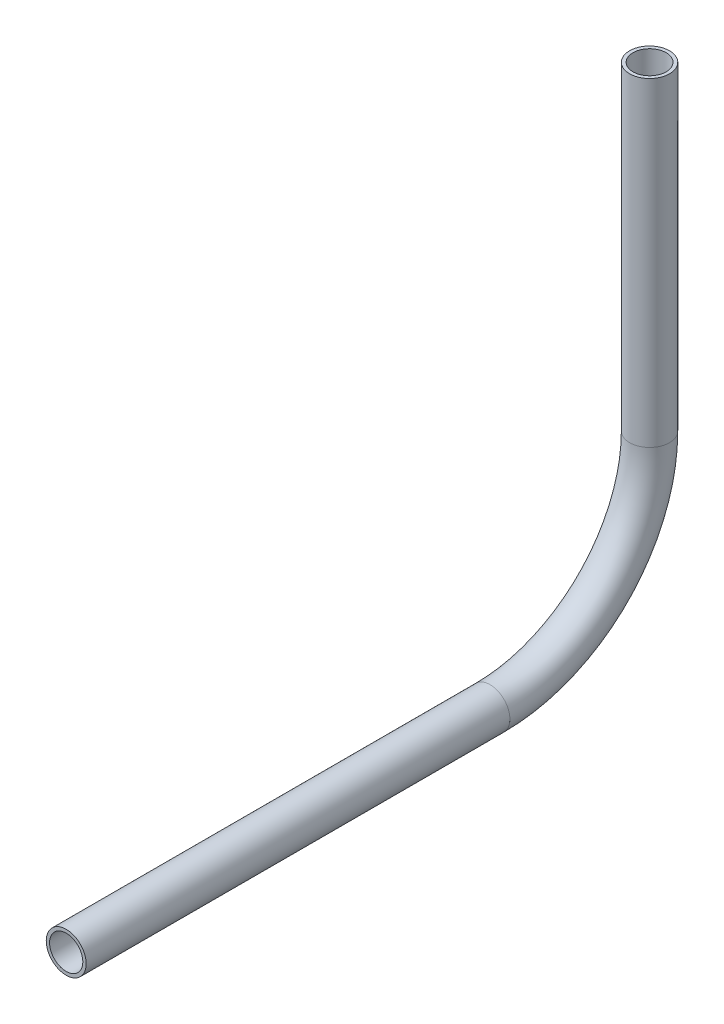
from build123d import *

# Parameters (mm, degrees)
SKETCH11_R                = 6.35
SKETCH11_R_2              = 5.2832
PIPE_0_5_SCH_40_1_DEPTH   = 134.891141117
SKETCH11_ON_SEGMENT_2_R   = 6.35
SKETCH11_ON_SEGMENT_2_R_2 = 5.2832
PIPE_0_5_SCH_40_1_2_ANGLE = 90
SKETCH11_ON_SEGMENT_3_R   = 6.35
SKETCH11_ON_SEGMENT_3_R_2 = 5.2832
PIPE_0_5_SCH_40_1_3_DEPTH = 101.698598989


with BuildPart() as part:
    # Sketch11 → Pipe 0.5 SCH 40(1) (new body)
    with BuildSketch(Plane(origin=(0, 599.960019272, 303.164595711), x_dir=(0, 1, 0), z_dir=(0, 0, -1))):
        Circle(SKETCH11_R)
        Circle(SKETCH11_R_2, mode=Mode.SUBTRACT)
    extrude(amount=PIPE_0_5_SCH_40_1_DEPTH)


with BuildPart() as body_2:
    # Sketch11 on segment 2 (carried to the start of arc 2) → Pipe 0.5 SCH 40_1 2 (revolve)
    with BuildSketch(Plane(origin=(0, 599.960019272, 168.273454594), x_dir=(0, 1, 0), z_dir=(0, 0, -1))):
        Circle(SKETCH11_ON_SEGMENT_2_R)
        Circle(SKETCH11_ON_SEGMENT_2_R_2, mode=Mode.SUBTRACT)
    revolve(axis=Axis((0, 650.760019272, 168.273454594), (1, 0, 0)), revolution_arc=PIPE_0_5_SCH_40_1_2_ANGLE)


with BuildPart() as body_3:
    # Sketch11 on segment 3 (carried to segment 3) → Pipe 0.5 SCH 40_1 3 (new body)
    with BuildSketch(Plane(origin=(0, 650.760019272, 117.473454594), x_dir=(0, 0, 1), z_dir=(0, 1, 0))):
        Circle(SKETCH11_ON_SEGMENT_3_R)
        Circle(SKETCH11_ON_SEGMENT_3_R_2, mode=Mode.SUBTRACT)
    extrude(amount=PIPE_0_5_SCH_40_1_3_DEPTH)


solid = Compound([part.part, body_2.part, body_3.part])
